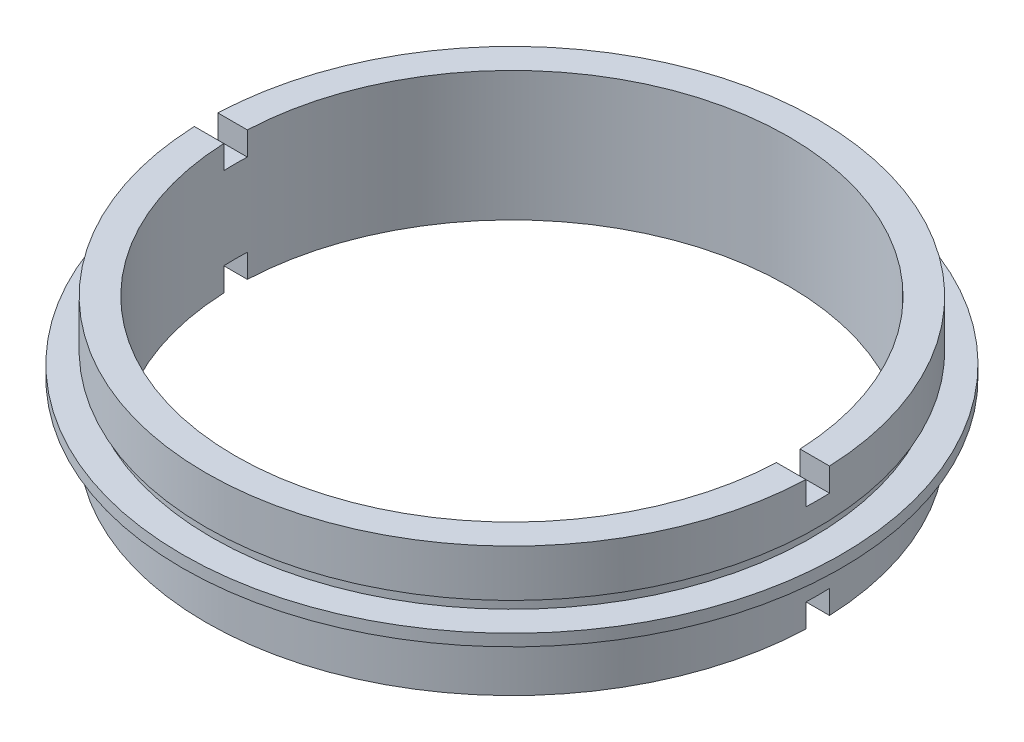
from build123d import *

# Parameters (mm, degrees)
SKETCH_2_W          = 2
SKETCH_2_H          = 4.593987872
SKETCH_2_H_2        = 6.667892238
CUT_EXTRUDE_1_DEPTH = 39.5


with BuildPart() as part:
    # 草图1 → 旋转1 (revolve)
    with BuildSketch(Plane.XY, mode=Mode.PRIVATE) as revolve_1_sk:
        Polygon((-23.5, 11), (-26, 11), (-26, 7), (-25.5, 7), (-25.5, 6), (-28, 6), (-28, 5), (-25.5, 5), (-25.5, 4), (-26, 4), (-26, 0), (-23.5, 0), align=None)
    revolve(revolve_1_sk.sketch.rotate(Axis((0, 22.677499451, 0), (0, -1, 0)), 270), axis=Axis((0, 22.677499451, 0), (0, -1, 0)))  # turned: the seam where the file's is

    # 草图2 → 切除-拉伸1 (cut, symmetric)
    with BuildSketch(Plane(origin=(0, 0, 0), x_dir=(0, 0, -1), z_dir=(1, 0, 0))):
        with Locations((0, 11.296993936)):
            Rectangle(SKETCH_2_W, SKETCH_2_H)
        with Locations((0, -1.333946119)):
            Rectangle(SKETCH_2_W, SKETCH_2_H_2)
    extrude(amount=CUT_EXTRUDE_1_DEPTH, both=True, mode=Mode.SUBTRACT)


solid = part.part
